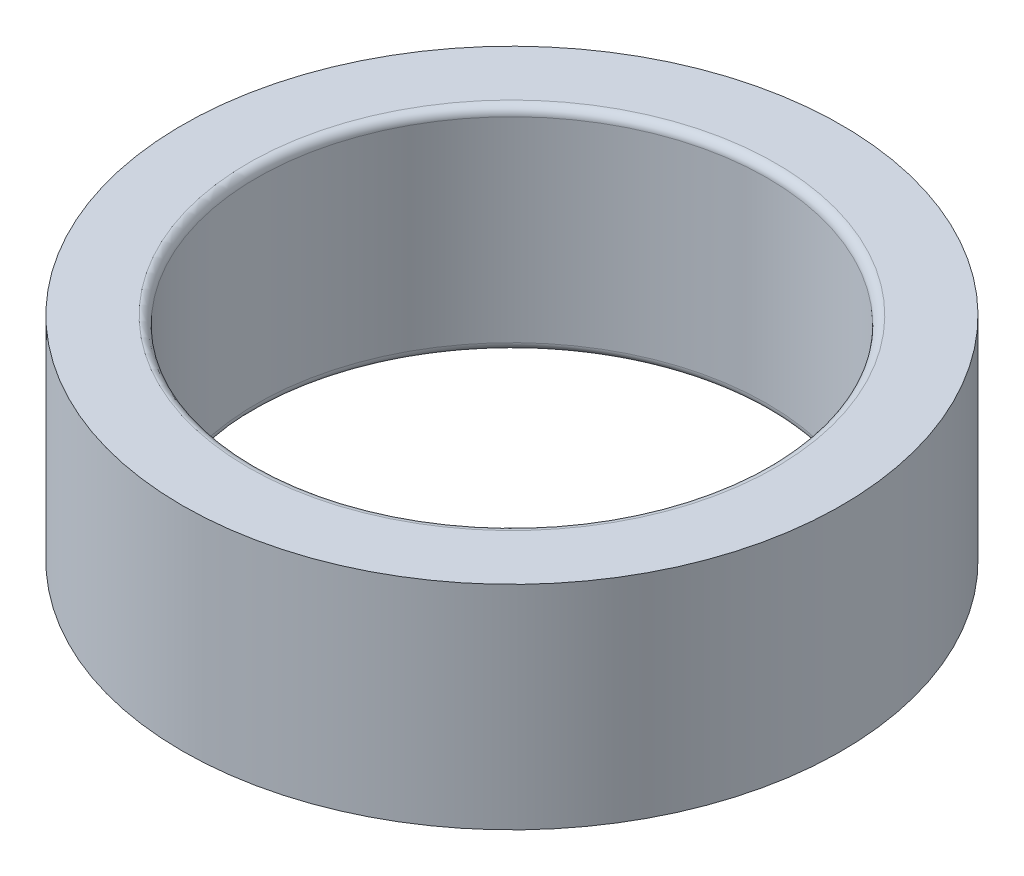
from build123d import *

# Parameters (mm, degrees)
SKETCH1_R           = 7.75
SKETCH1_R_2         = 6
BOSS_EXTRUDE1_DEPTH = 5
FILLET1_R           = 0.2


with BuildPart() as part:
    # Sketch1 → Boss-Extrude1 (new body)
    with BuildSketch(Plane(origin=(0, 0, 0), x_dir=(1, 0, 0), z_dir=(0, 1, 0))):
        Circle(SKETCH1_R)
        Circle(SKETCH1_R_2, mode=Mode.SUBTRACT)
    extrude(amount=BOSS_EXTRUDE1_DEPTH)

    # Fillet1
    fillet1_edges = [part.edges().sort_by_distance(p)[0] for p in [
        (-6, 0, 0),
        (-6, 5, 0),
    ]]
    fillet(fillet1_edges, radius=FILLET1_R)


solid = part.part
